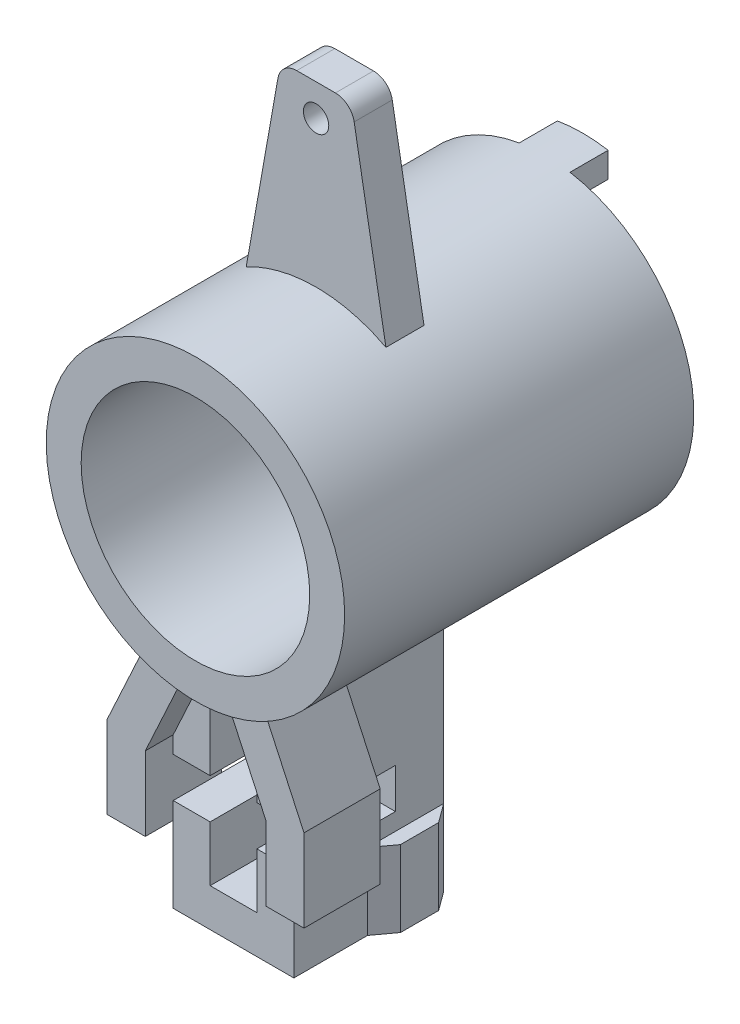
from build123d import *

# Parameters (mm, degrees)
SKETCH1_R           = 5.969
SKETCH1_R_2         = 4.572
BASE_EXTRUDE_DEPTH  = 13.97
BOSS_EXTRUDE1_DEPTH = 7.112
SKETCH3_W           = 4.826
SKETCH3_H           = 3.048
CUT_EXTRUDE1_DEPTH  = 1.524
CUT_EXTRUDE2_START  = -6.605477
SKETCH4_W           = 1.524
SKETCH4_H           = 4.064
CUT_EXTRUDE2_DEPTH  = 6.605477
CUT_EXTRUDE3_REACH  = 10.382
SKETCH5_R           = 0.8001
BOSS_EXTRUDE2_DEPTH = 1.524
SKETCH7_R           = 0.508
CUT_EXTRUDE4_DEPTH  = 10.144
BOSS_EXTRUDE3_DEPTH = 1.524
BOSS_EXTRUDE4_START = -3.048
BOSS_EXTRUDE4_DEPTH = 3.048
CUT_EXTRUDE5_START  = -1.1176
CUT_EXTRUDE5_DEPTH  = 1.1176
CUT_EXTRUDE6_DEPTH  = 4.064


with BuildPart() as part:
    # Sketch1 → Base-Extrude (new body)
    with BuildSketch(Plane.XY):
        Circle(SKETCH1_R)
        Circle(SKETCH1_R_2, mode=Mode.SUBTRACT)
    extrude(amount=BASE_EXTRUDE_DEPTH)

    # Sketch2 → Boss-Extrude1 (add)
    with BuildSketch(Plane.XY.offset(13.5636)):
        with BuildLine():
            Line((-2.413, -5.459523056), (-3.937, -8.763))
            Line((-3.937, -8.763), (-3.937, -12.065))
            Line((-3.937, -12.065), (-2.413, -12.065))
            Line((-2.413, -12.065), (-2.413, -15.113))
            Line((-2.413, -15.113), (2.413, -15.113))
            Line((2.413, -15.113), (2.413, -12.065))
            Line((2.413, -12.065), (3.937, -12.065))
            Line((3.937, -12.065), (3.937, -8.763))
            Line((3.937, -8.763), (2.413, -5.459523056))
            ThreePointArc((2.413, -5.459523056), (0, -5.969), (-2.413, -5.459523056))
        make_face()
    extrude(amount=-BOSS_EXTRUDE1_DEPTH)

    # Sketch3 → Cut-Extrude1 (cut)
    with BuildSketch(Plane.XY.offset(13.97)):
        with Locations((0, -13.589)):
            Rectangle(SKETCH3_W, SKETCH3_H)
    extrude(amount=-CUT_EXTRUDE1_DEPTH, mode=Mode.SUBTRACT)

    # Sketch4 → Cut-Extrude2 (cut)
    with BuildSketch(Plane.XZ.offset(12.065).offset(CUT_EXTRUDE2_START)):
        with Locations((3.175, 8.4836)):
            Rectangle(SKETCH4_W, SKETCH4_H)
        with Locations((-3.175, 8.4836)):
            Rectangle(SKETCH4_W, SKETCH4_H)
    extrude(amount=CUT_EXTRUDE2_DEPTH, mode=Mode.SUBTRACT)

    # Sketch5 → Cut-Extrude3 (cut, up to next)
    with BuildSketch(Plane(origin=(2.413, 0, 0), x_dir=(0, 0, -1), z_dir=(1, 0, 0)), mode=Mode.PRIVATE) as cut_extrude3_sk1:
        with Locations((-9.7155, -10.577465123)):
            Circle(SKETCH5_R)
    cut_extrude3_tool1 = extrude(cut_extrude3_sk1.sketch, amount=-CUT_EXTRUDE3_REACH, mode=Mode.PRIVATE) & part.part
    add(cut_extrude3_tool1.solids().sort_by_distance((2.413, -10.577465, 9.7155))[0], mode=Mode.SUBTRACT)

    # Sketch6 → Boss-Extrude2 (add)
    with BuildSketch(Plane.XY.offset(9.144)):
        with BuildLine():
            Line((-2.794, 5.274706153), (-1.524, 12.451775059))
            ThreePointArc((-1.524, 12.451775059), (-1.263283995, 12.902874385), (-0.773656889, 13.081))
            Line((-0.773656889, 13.081), (0.773656889, 13.081))
            ThreePointArc((0.773656889, 13.081), (1.263283995, 12.902874385), (1.524, 12.451775059))
            Line((1.524, 12.451775059), (2.794, 5.274706153))
            ThreePointArc((2.794, 5.274706153), (0, 5.969), (-2.794, 5.274706153))
        make_face()
    extrude(amount=-BOSS_EXTRUDE2_DEPTH)

    # Sketch7 → Cut-Extrude4 (cut, through all)
    with BuildSketch(Plane.XY.offset(9.144)):
        with Locations((0, 11.811)):
            Circle(SKETCH7_R)
    extrude(amount=-CUT_EXTRUDE4_DEPTH, mode=Mode.SUBTRACT)

    # Sketch8 → Boss-Extrude3 (add)
    with BuildSketch(Plane(origin=(0, 0, 0), x_dir=(-1, 0, 0), z_dir=(0, 0, -1))):
        with BuildLine():
            Line((-1.016, 4.873623966), (-1.016, 5.881896378))
            ThreePointArc((-1.016, 5.881896378), (0, 5.969), (1.016, 5.881896378))
            Line((1.016, 5.881896378), (1.016, 4.873623966))
            ThreePointArc((1.016, 4.873623966), (0, 4.9784), (-1.016, 4.873623966))
        make_face()
    extrude(amount=BOSS_EXTRUDE3_DEPTH)

    # Sketch9 → Boss-Extrude4 (add)
    with BuildSketch(Plane.XZ.offset(15.113).offset(BOSS_EXTRUDE4_START)):
        Polygon((2.413, 9.4996), (2.9718, 8.7376), (2.9718, 7.2136), (2.413, 6.4516), align=None)
        Polygon((-2.413, 9.4996), (-2.9718, 8.7376), (-2.9718, 7.2136), (-2.413, 6.4516), align=None)
    extrude(amount=BOSS_EXTRUDE4_DEPTH)

    # Sketch10 → Cut-Extrude5 (cut)
    with BuildSketch(Plane.XY.offset(13.5636).offset(CUT_EXTRUDE5_START)):
        with BuildLine():
            Line((-2.413, -12.065), (2.413, -12.065))
            Line((2.413, -12.065), (2.413, -9.097590664))
            Line((2.413, -9.097590664), (0.935640411, -5.895213145))
            ThreePointArc((0.935640411, -5.895213145), (0, -5.969), (-0.935640411, -5.895213145))
            Line((-0.935640411, -5.895213145), (-2.413, -9.097590664))
            Line((-2.413, -9.097590664), (-2.413, -12.065))
        make_face()
    extrude(amount=CUT_EXTRUDE5_DEPTH, mode=Mode.SUBTRACT)

    # Sketch12 → Cut-Extrude6 (cut)
    with BuildSketch(Plane.XY.offset(12.446)):
        with BuildLine():
            Line((0.935640411, -5.895213145), (0.935640411, -9.777365123))
            Line((0.935640411, -9.777365123), (2.413, -9.777365123))
            Line((2.413, -9.777365123), (2.413, -11.377565123))
            Line((2.413, -11.377565123), (0.935640411, -11.377565123))
            Line((0.935640411, -11.377565123), (0.935640411, -13.589))
            Line((0.935640411, -13.589), (-0.935640411, -13.589))
            Line((-0.935640411, -13.589), (-0.935640411, -11.377565123))
            Line((-0.935640411, -11.377565123), (-2.413, -11.377565123))
            Line((-2.413, -11.377565123), (-2.413, -9.777365123))
            Line((-2.413, -9.777365123), (-0.935640411, -9.777365123))
            Line((-0.935640411, -9.777365123), (-0.935640411, -5.895213145))
            ThreePointArc((-0.935640411, -5.895213145), (0, -5.969), (0.935640411, -5.895213145))
        make_face()
    extrude(amount=-CUT_EXTRUDE6_DEPTH, mode=Mode.SUBTRACT)


solid = part.part
